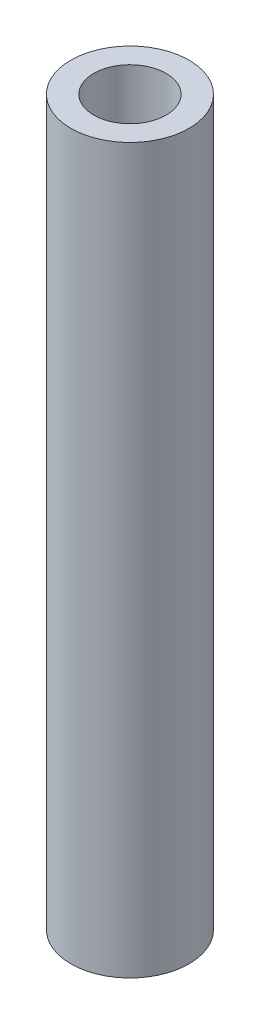
from build123d import *

# Parameters (mm, degrees)
ESQUISSE1_R        = 2.45
ESQUISSE1_R_2      = 1.5
BOSS_EXTRU_1_DEPTH = 30


with BuildPart() as part:
    # Esquisse1 → Boss.-Extru.1 (new body)
    with BuildSketch(Plane(origin=(0, 0, 0), x_dir=(1, 0, 0), z_dir=(0, 1, 0))):
        Circle(ESQUISSE1_R)
        Circle(ESQUISSE1_R_2, mode=Mode.SUBTRACT)
    extrude(amount=BOSS_EXTRU_1_DEPTH)


solid = part.part
